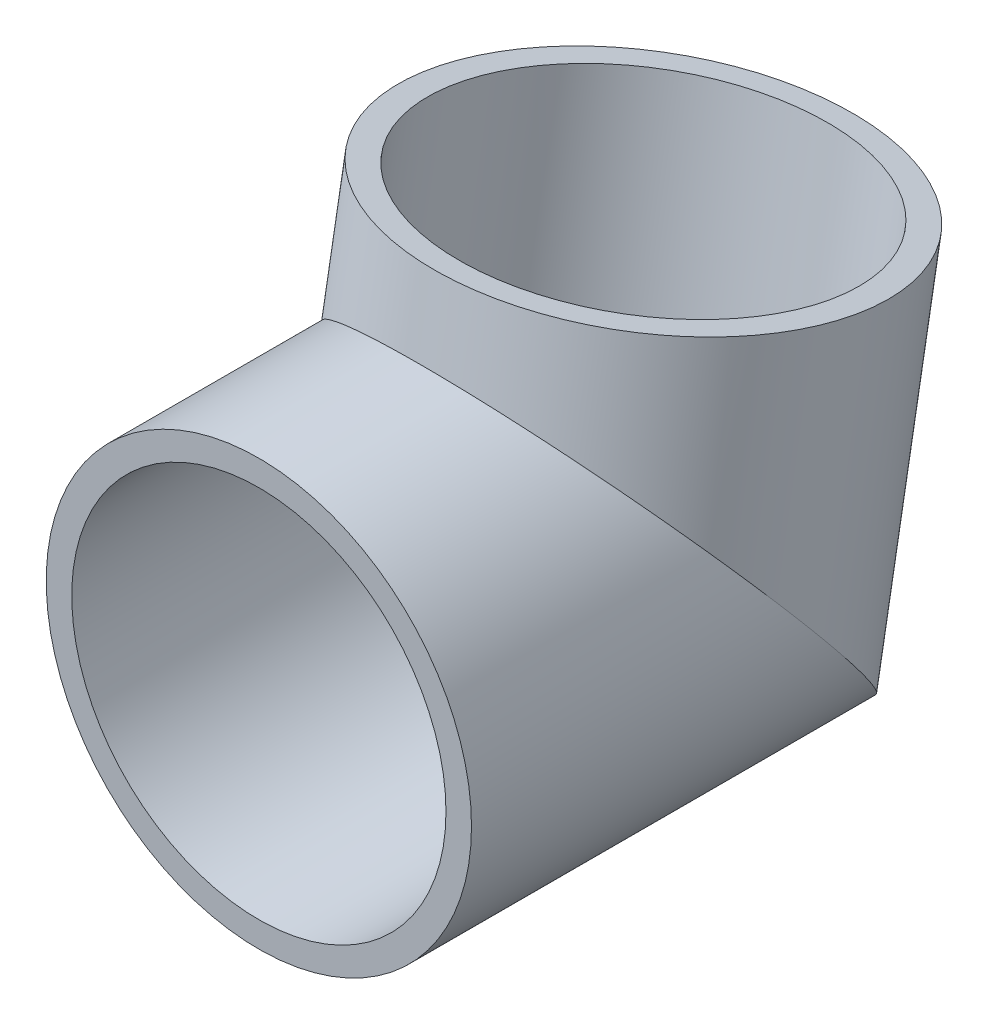
from build123d import *

# Parameters (mm, degrees)
SKETCH3_R   = 25
SKETCH3_R_2 = 22


with BuildPart() as part:
    # Sweep1: sweep along a path in Sketch1
    with BuildLine(Plane(origin=(0, 0, 0), x_dir=(0, 0, -1), z_dir=(1, 0, 0))) as sweep1_path:
        Line((0, 0), (40, 0))
        Line((40, 0), (45.20944533, 29.54423259))
    # Sketch3 → Sweep1 (sweep)
    with BuildSketch(Plane.XY):
        Circle(SKETCH3_R)
        Circle(SKETCH3_R_2, mode=Mode.SUBTRACT)
    sweep(path=sweep1_path.line, transition=Transition.RIGHT)


solid = part.part
